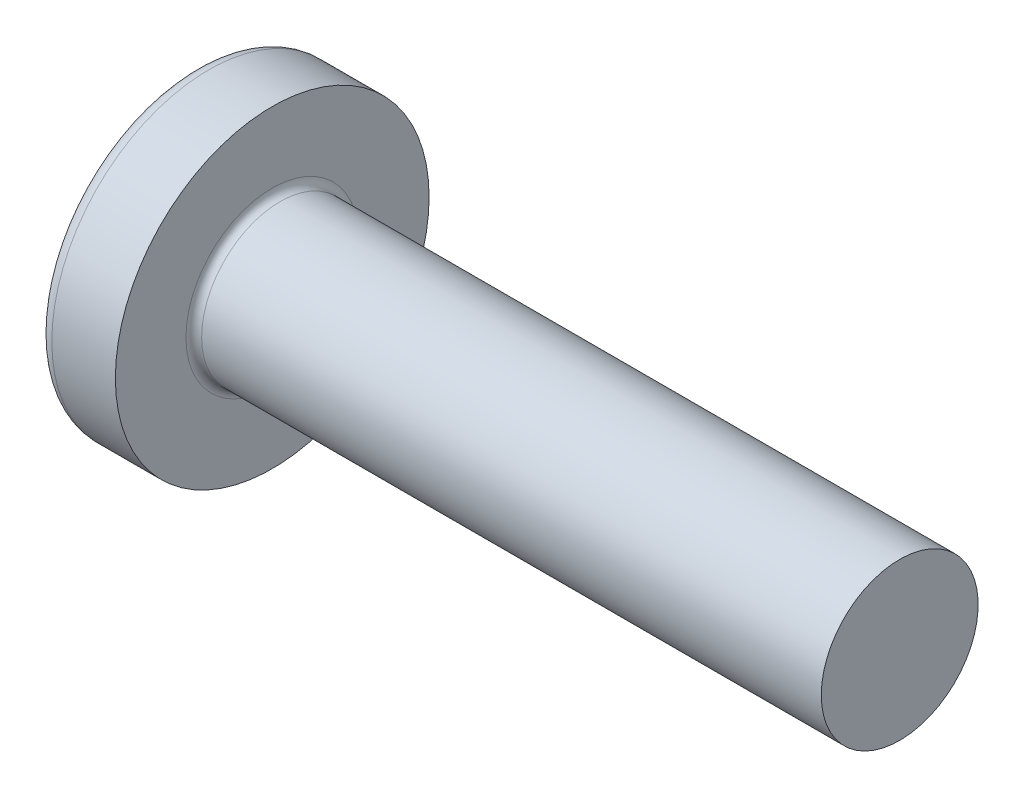
from build123d import *

# Parameters (mm, degrees)
FILLET1_R    = 0.1
SKETCH3_W    = 0.48
SKETCH3_H    = 2.1
SKETCH4_W    = 0.48
SKETCH4_H    = 0.684028282
RECPAT_COUNT = 2
RECPAT_ANGLE = 90


with BuildPart() as part:
    # BodySke → Base-Revolve (revolve)
    with BuildSketch(Plane.XY, mode=Mode.PRIVATE) as base_revolve_sk:
        with BuildLine():
            Line((1.6, 1), (1.6, 2))
            Line((1.6, 2), (0.790020747, 2))
            ThreePointArc((0.790020747, 2), (0.709789294, 1.981130115), (0.646379599, 1.928476821))
            ThreePointArc((0.646379599, 1.928476821), (0.165895084, 1.016959861), (0, 0))
            Line((0, 0), (9.6, 0))
            Line((9.6, 0), (9.6, 1))
            Line((9.6, 1), (1.6, 1))
        make_face()
    revolve(base_revolve_sk.sketch.rotate(Axis((-25.4, 0, 0), (1, 0, 0)), 90), axis=Axis((-25.4, 0, 0), (1, 0, 0)))  # turned: the seam where the file's is

    # Fillet1
    fillet1_edges = [part.edges().sort_by_distance(p)[0] for p in [
        (1.6, 0, -1),
    ]]
    fillet(fillet1_edges, radius=FILLET1_R)

    # Sketch3 → Recess section 0
    with BuildSketch(Plane(origin=(0, 0, 0), x_dir=(0, 0, -1), z_dir=(1, 0, 0))):
        Rectangle(SKETCH3_W, SKETCH3_H)
    # Sketch4 → Recess section 1
    with BuildSketch(Plane(origin=(1.42, 0, 0), x_dir=(0, 0, -1), z_dir=(1, 0, 0))):
        Rectangle(SKETCH4_W, SKETCH4_H)
    recess = loft(mode=Mode.SUBTRACT)

    # RecPat: Recess ×2 about axis
    recpat_axis = Axis((0, 0, 0), (1, 0, 0))
    for i in range(1, RECPAT_COUNT):
        add(recess.rotate(recpat_axis, i * RECPAT_ANGLE / (RECPAT_COUNT - 1)), mode=Mode.SUBTRACT)

    # RecCorSke → RecessCore (revolve, cut)
    with BuildSketch(Plane.XY, mode=Mode.PRIVATE) as recesscore_sk:
        Polygon((0, 0), (0, 0.454796073), (1.42, 0.3555), (1.535508952, 0), align=None)
    revolve(recesscore_sk.sketch.rotate(Axis((-3.175, 0, 0), (1, 0, 0)), 90), axis=Axis((-3.175, 0, 0), (1, 0, 0)), mode=Mode.SUBTRACT)  # turned: the seam where the file's is


solid = part.part
